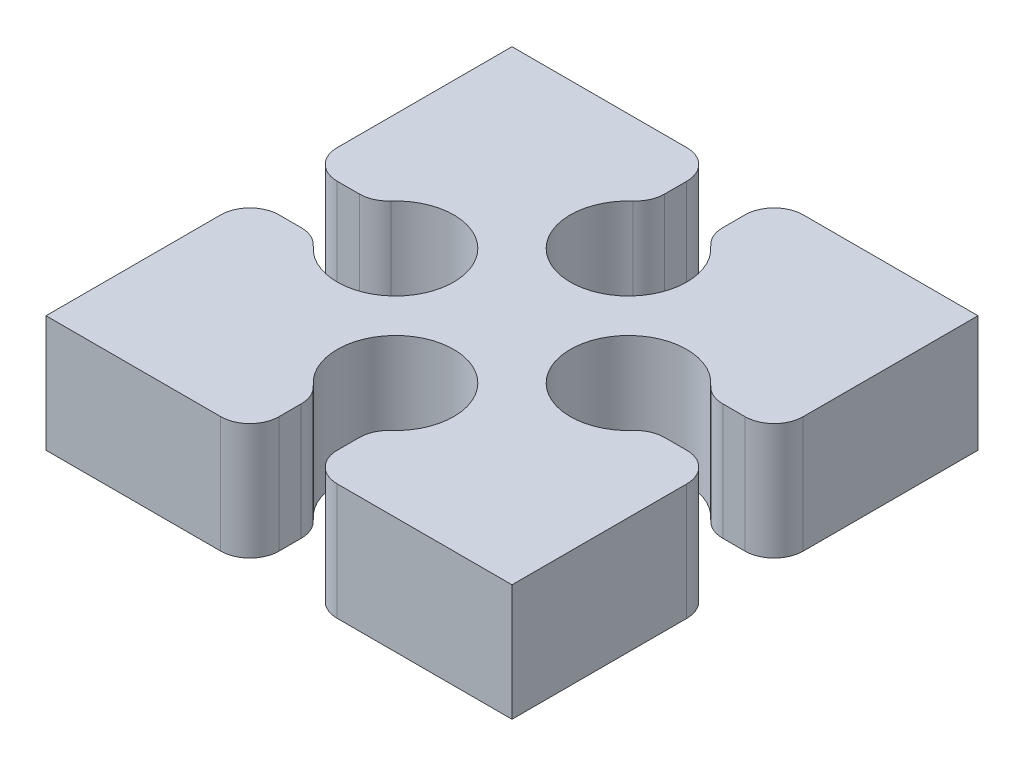
from build123d import *

# Parameters (mm, degrees)
BOSS_EXTRUDE1_DEPTH = 2
FILLET1_R           = 0.5


with BuildPart() as part:
    # Sketch1 → Boss-Extrude1 (new body)
    with BuildSketch(Plane(origin=(0, 0, 0), x_dir=(1, 0, 0), z_dir=(0, 1, 0))):
        with BuildLine():
            Line((-0.5, 4), (-4, 4))
            Line((-4, 4), (-4, 0.5))
            Line((-4, 0.5), (-2.866025404, 0.5))
            ThreePointArc((-2.866025404, 0.5), (-1.741180955, 0.965925826), (-1, 0))
            ThreePointArc((-1, 0), (-1.741180955, -0.965925826), (-2.866025404, -0.5))
            Line((-2.866025404, -0.5), (-4, -0.5))
            Line((-4, -0.5), (-4, -4))
            Line((-4, -4), (-0.5, -4))
            Line((-0.5, -4), (-0.5, -2.866025404))
            ThreePointArc((-0.5, -2.866025404), (-0.5, -1.133974596), (1, -2))
            ThreePointArc((1, -2), (0.866025404, -2.5), (0.5, -2.866025404))
            Line((0.5, -2.866025404), (0.5, -4))
            Line((0.5, -4), (4, -4))
            Line((4, -4), (4, -0.5))
            Line((4, -0.5), (2.866025404, -0.5))
            ThreePointArc((2.866025404, -0.5), (1, 0), (2.866025404, 0.5))
            Line((2.866025404, 0.5), (4, 0.5))
            Line((4, 0.5), (4, 4))
            Line((4, 4), (0.5, 4))
            Line((0.5, 4), (0.5, 2.866025404))
            ThreePointArc((0.5, 2.866025404), (0.866025404, 2.5), (1, 2))
            ThreePointArc((1, 2), (-0.5, 1.133974596), (-0.5, 2.866025404))
            Line((-0.5, 2.866025404), (-0.5, 4))
        make_face()
    extrude(amount=BOSS_EXTRUDE1_DEPTH)

    # Fillet1
    fillet1_edges = [part.edges().sort_by_distance(p)[0] for p in [
        (-2.866025404, 1, -0.5),
        (-4, 1, -0.5),
        (-0.5, 1, -4),
        (-0.5, 1, -2.866025404),
        (0.5, 1, -2.866025404),
        (0.5, 1, -4),
        (4, 1, -0.5),
        (2.866025404, 1, -0.5),
        (2.866025404, 1, 0.5),
        (4, 1, 0.5),
        (0.5, 1, 4),
        (0.5, 1, 2.866025404),
        (-0.5, 1, 2.866025404),
        (-0.5, 1, 4),
        (-4, 1, 0.5),
        (-2.866025404, 1, 0.5),
    ]]
    fillet(fillet1_edges, radius=FILLET1_R)


solid = part.part
